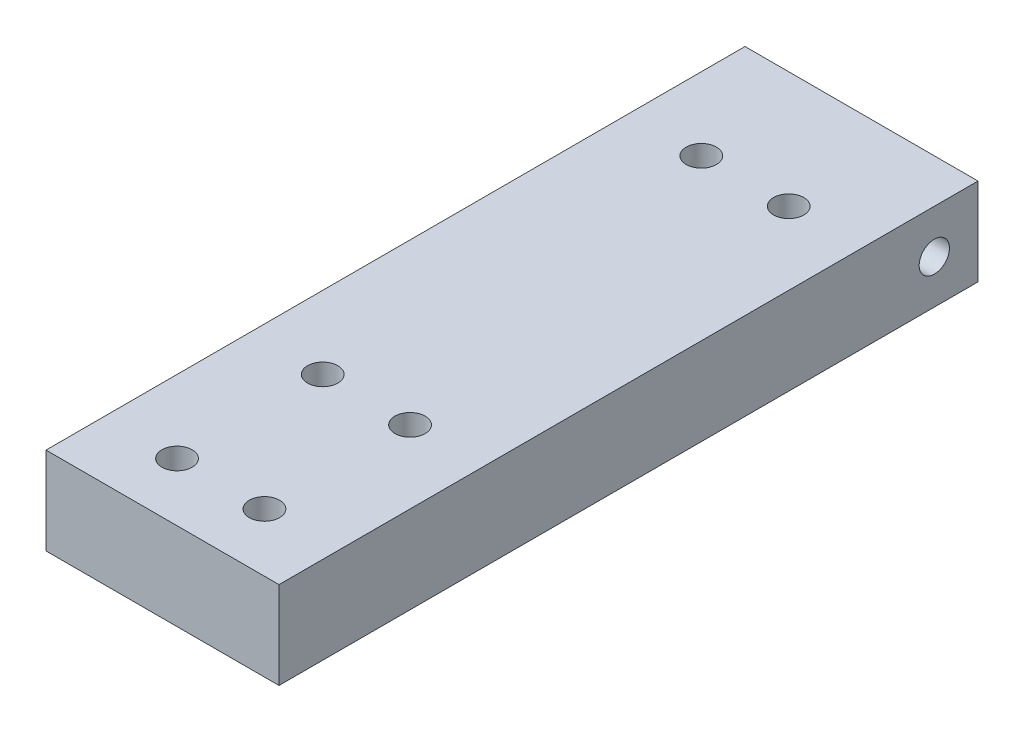
from build123d import *

# Parameters (mm, degrees)
SKETCH1_W                      = 50.8
SKETCH1_H                      = 19.05
BOSS_EXTRUDE1_DEPTH            = 152.4
CBORE_FOR_M6_SHCS1_D           = 6.6
CBORE_FOR_M6_SHCS1_CBORE_D     = 11
CBORE_FOR_M6_SHCS1_CBORE_DEPTH = 12.35
M6_CLEARANCE_HOLE1_D           = 6.6
M6_CLEARANCE_HOLE2_D           = 6.6


with BuildPart() as part:
    # Sketch1 → Boss-Extrude1 (new body)
    with BuildSketch(Plane.XY):
        with Locations((25.4, 9.525)):
            Rectangle(SKETCH1_W, SKETCH1_H)
    extrude(amount=BOSS_EXTRUDE1_DEPTH)

    # CBORE for M6 SHCS1 (through all)
    with Locations(Plane(origin=(0, 0, 0), x_dir=(-1, 0, 0), z_dir=(0, -1, 0))):
        with Locations((-34.925, -139.7), (-34.925, -107.95), (-15.875, -107.95), (-15.875, -139.7)):
            CounterBoreHole(CBORE_FOR_M6_SHCS1_D / 2, CBORE_FOR_M6_SHCS1_CBORE_D / 2, CBORE_FOR_M6_SHCS1_CBORE_DEPTH)

    # M6 Clearance Hole1 (through all)
    with Locations(Plane.ZY):
        with Locations((9.525, 9.525)):
            Hole(M6_CLEARANCE_HOLE1_D / 2)

    # M6 Clearance Hole2 (through all)
    with Locations(Plane(origin=(0, 0, 0), x_dir=(-1, 0, 0), z_dir=(0, -1, 0))):
        with Locations((-34.925, -25.4), (-15.875, -25.4)):
            Hole(M6_CLEARANCE_HOLE2_D / 2)


solid = part.part
